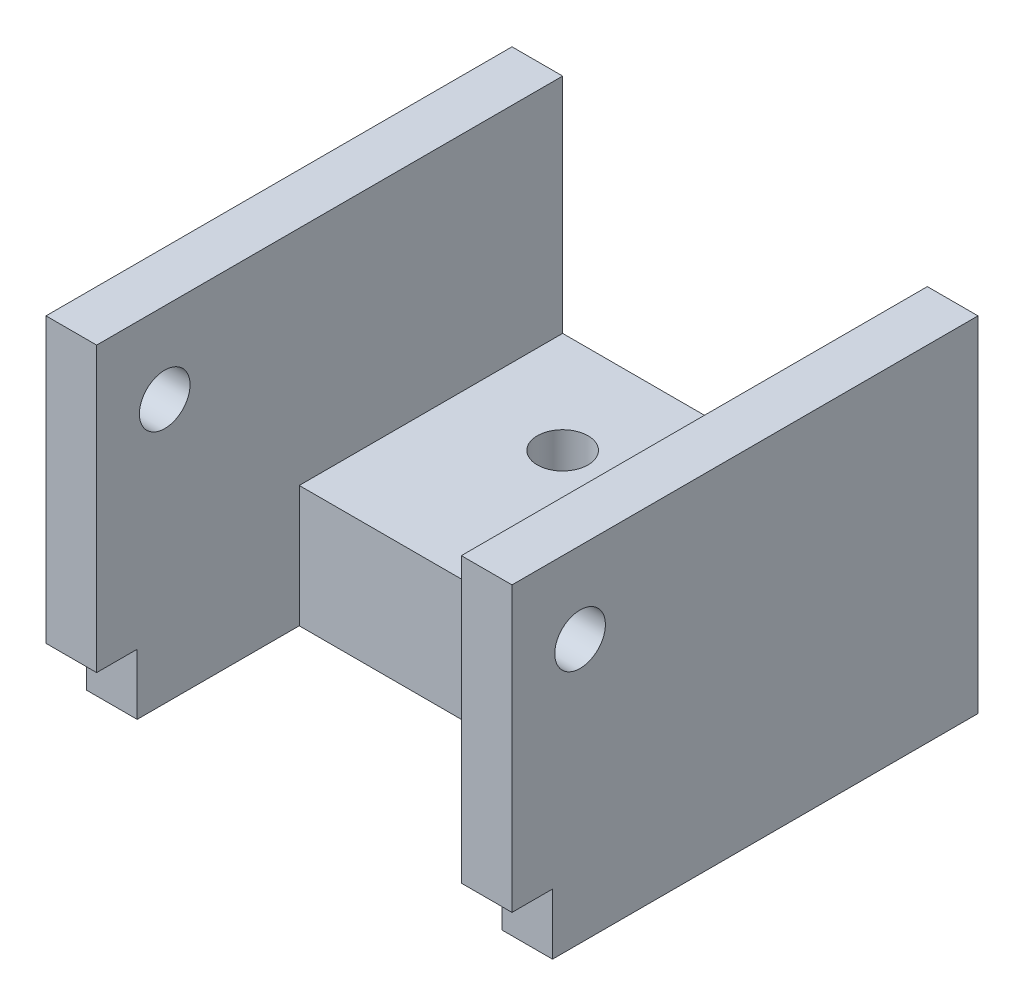
from build123d import *

# Parameters (mm, degrees)
SKETCH1_W           = 23
SKETCH1_H           = 17
BOSS_EXTRUDE1_DEPTH = 2.5
SKETCH2_W           = 13
SKETCH2_H           = 6
BOSS_EXTRUDE2_DEPTH = 18
SKETCH3_W           = 23
SKETCH3_H           = 17
BOSS_EXTRUDE3_DEPTH = 2.5
SKETCH5_W           = 2
SKETCH5_H           = 3
CUT_EXTRUDE1_DEPTH  = 24
SKETCH4_R           = 1.25
CUT_EXTRUDE3_DEPTH  = 24
SKETCH7_R           = 1.25
CUT_EXTRUDE4_DEPTH  = 10


with BuildPart() as part:
    # Sketch1 → Boss-Extrude1 (new body)
    with BuildSketch(Plane(origin=(0, 0, 0), x_dir=(0, 0, -1), z_dir=(1, 0, 0))):
        with Locations((-39.471099191, 23.847043717)):
            Rectangle(SKETCH1_W, SKETCH1_H)
    extrude(amount=BOSS_EXTRUDE1_DEPTH)

    # Sketch2 → Boss-Extrude2 (add)
    with BuildSketch(Plane(origin=(2.5, 0, 0), x_dir=(0, 0, -1), z_dir=(1, 0, 0))):
        with Locations((-34.471099191, 18.347043717)):
            Rectangle(SKETCH2_W, SKETCH2_H)
    extrude(amount=BOSS_EXTRUDE2_DEPTH)

    # Sketch3 → Boss-Extrude3 (add)
    with BuildSketch(Plane(origin=(20.5, 0, 0), x_dir=(0, 0, -1), z_dir=(1, 0, 0))):
        with Locations((-39.471099191, 23.847043717)):
            Rectangle(SKETCH3_W, SKETCH3_H)
    extrude(amount=BOSS_EXTRUDE3_DEPTH)

    # Sketch5 → Cut-Extrude1 (cut, through all)
    with BuildSketch(Plane(origin=(23, 0, 0), x_dir=(0, 0, -1), z_dir=(1, 0, 0))):
        with Locations((-49.971099191, 16.847043717)):
            Rectangle(SKETCH5_W, SKETCH5_H)
    extrude(amount=-CUT_EXTRUDE1_DEPTH, mode=Mode.SUBTRACT)

    # Sketch4 → Cut-Extrude3 (cut, through all)
    with BuildSketch(Plane(origin=(23, 0, 0), x_dir=(0, 0, -1), z_dir=(1, 0, 0))):
        with Locations((-47.611099191, 28.347043717)):
            Circle(SKETCH4_R)
    extrude(amount=-CUT_EXTRUDE3_DEPTH, mode=Mode.SUBTRACT)

    # Sketch7 → Cut-Extrude4 (cut)
    with BuildSketch(Plane(origin=(0, 21.347043717, 0), x_dir=(1, 0, 0), z_dir=(0, 1, 0))):
        with Locations((7.5, -32.971099191)):
            Circle(SKETCH7_R)
        with Locations((15.5, -32.971099191)):
            Circle(SKETCH7_R)
    extrude(amount=-CUT_EXTRUDE4_DEPTH, mode=Mode.SUBTRACT)


solid = part.part
